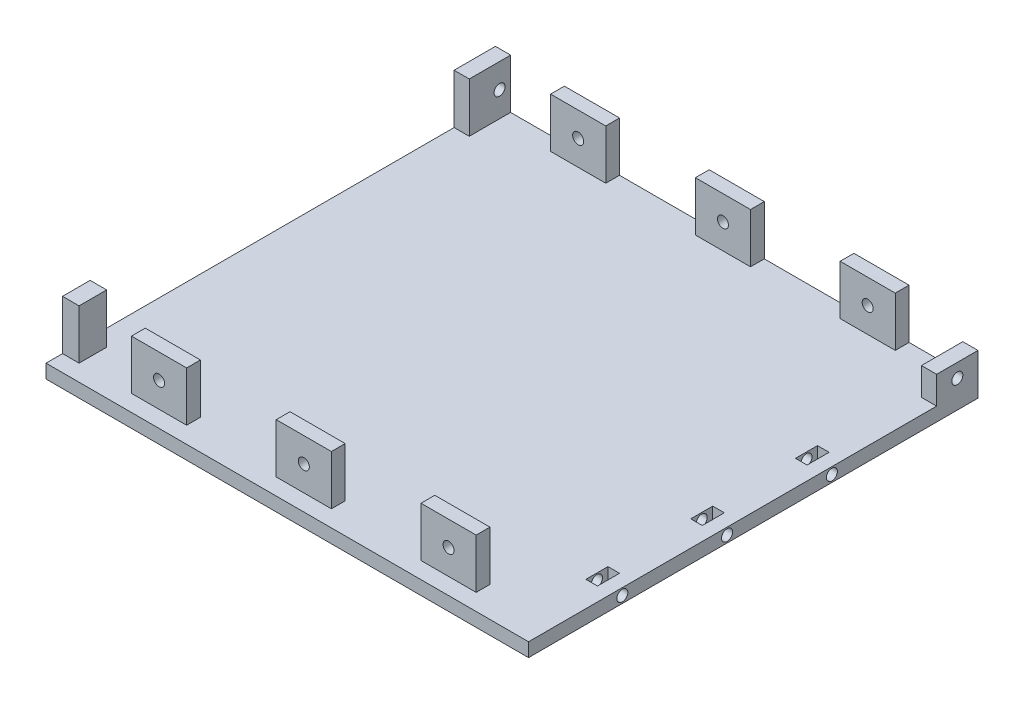
from build123d import *

# Parameters (mm, degrees)
SKETCH1_W               = 175
SKETCH1_H               = 163
BOSS_EXTRUDE1_DEPTH     = 5
SKETCH2_W               = 20
SKETCH2_H               = 5
BOSS_EXTRUDE2_DEPTH     = 18
SKETCH3_R               = 2
CUT_EXTRUDE1_DEPTH      = 7
CUT_EXTRUDE1_DEPTH_BACK = 158
SKETCH4_W               = 5.5
SKETCH4_H               = 15
SKETCH4_W_2             = 6
SKETCH4_H_2             = 10
BOSS_EXTRUDE3_DEPTH     = 18
SKETCH5_R               = 2
CUT_EXTRUDE2_DEPTH      = 18
SKETCH6_W               = 5.5
SKETCH6_H               = 15
BOSS_EXTRUDE4_DEPTH     = 10
SKETCH7_R               = 2
CUT_EXTRUDE3_DEPTH      = 10
SKETCH8_W               = 4.2
SKETCH8_H               = 8
CUT_EXTRUDE4_DEPTH      = 10
SKETCH9_R               = 2
CUT_EXTRUDE5_DEPTH      = 18


with BuildPart() as part:
    # Sketch1 → Boss-Extrude1 (new body)
    with BuildSketch(Plane(origin=(0, 0, 0), x_dir=(1, 0, 0), z_dir=(0, 1, 0))):
        with Locations((-64.046391753, -12.943298969)):
            Rectangle(SKETCH1_W, SKETCH1_H)
    extrude(amount=BOSS_EXTRUDE1_DEPTH)

    # Sketch2 → Boss-Extrude2 (add)
    with BuildSketch(Plane(origin=(0, 5, 0), x_dir=(1, 0, 0), z_dir=(0, 1, 0))):
        with Locations((-116.546391753, 66.056701031)):
            Rectangle(SKETCH2_W, SKETCH2_H)
        with Locations((-116.546391753, -85.943298969)):
            Rectangle(SKETCH2_W, SKETCH2_H)
        with Locations((-11.546391753, -85.943298969)):
            Rectangle(SKETCH2_W, SKETCH2_H)
        with Locations((-11.546391753, 66.056701031)):
            Rectangle(SKETCH2_W, SKETCH2_H)
        with Locations((-64.046391753, -85.943298969)):
            Rectangle(SKETCH2_W, SKETCH2_H)
        with Locations((-64.046391753, 66.056701031)):
            Rectangle(SKETCH2_W, SKETCH2_H)
    extrude(amount=BOSS_EXTRUDE2_DEPTH)

    # Sketch3 → Cut-Extrude1 (cut, two sides)
    with BuildSketch(Plane.XY.offset(88.443298969)) as cut_extrude1_sk:
        with Locations((-116.546391753, 14.1)):
            Circle(SKETCH3_R)
        with Locations((-64.046391753, 14.1)):
            Circle(SKETCH3_R)
        with Locations((-11.546391753, 14.1)):
            Circle(SKETCH3_R)
    extrude(amount=CUT_EXTRUDE1_DEPTH, mode=Mode.SUBTRACT)
    extrude(cut_extrude1_sk.sketch, amount=-CUT_EXTRUDE1_DEPTH_BACK, mode=Mode.SUBTRACT)

    # Sketch4 → Boss-Extrude3 (add)
    with BuildSketch(Plane(origin=(0, 5, 0), x_dir=(1, 0, 0), z_dir=(0, 1, 0))):
        with Locations((-148.796391753, 61.056701031)):
            Rectangle(SKETCH4_W, SKETCH4_H)
        with Locations((-148.546391753, -83.443298969)):
            Rectangle(SKETCH4_W_2, SKETCH4_H_2)
    extrude(amount=BOSS_EXTRUDE3_DEPTH)

    # Sketch5 → Cut-Extrude2 (cut)
    with BuildSketch(Plane(origin=(-146.046391753, 0, 0), x_dir=(0, 0, -1), z_dir=(1, 0, 0))):
        with Locations((64.556701031, 14.1)):
            Circle(SKETCH5_R)
    extrude(amount=-CUT_EXTRUDE2_DEPTH, mode=Mode.SUBTRACT)

    # Sketch6 → Boss-Extrude4 (add)
    with BuildSketch(Plane(origin=(0, 5, 0), x_dir=(1, 0, 0), z_dir=(0, 1, 0))):
        with Locations((20.703608247, 61.056701031)):
            Rectangle(SKETCH6_W, SKETCH6_H)
    extrude(amount=BOSS_EXTRUDE4_DEPTH)

    # Sketch7 → Cut-Extrude3 (cut)
    with BuildSketch(Plane(origin=(23.453608247, 0, 0), x_dir=(0, 0, -1), z_dir=(1, 0, 0))):
        with Locations((61.056701031, 10)):
            Circle(SKETCH7_R)
    extrude(amount=-CUT_EXTRUDE3_DEPTH, mode=Mode.SUBTRACT)

    # Sketch8 → Cut-Extrude4 (cut)
    with BuildSketch(Plane(origin=(0, 5, 0), x_dir=(1, 0, 0), z_dir=(0, 1, 0))):
        with Locations((16.353608247, -60.443298969)):
            Rectangle(SKETCH8_W, SKETCH8_H)
        with Locations((16.353608247, -22.443298969)):
            Rectangle(SKETCH8_W, SKETCH8_H)
        with Locations((16.353608247, 15.556701031)):
            Rectangle(SKETCH8_W, SKETCH8_H)
    extrude(amount=-CUT_EXTRUDE4_DEPTH, mode=Mode.SUBTRACT)

    # Sketch9 → Cut-Extrude5 (cut)
    with BuildSketch(Plane(origin=(23.453608247, 0, 0), x_dir=(0, 0, -1), z_dir=(1, 0, 0))):
        with Locations((-60.443298969, 2.5)):
            Circle(SKETCH9_R)
        with Locations((15.556701031, 2.5)):
            Circle(SKETCH9_R)
        with Locations((-22.443298969, 2.5)):
            Circle(SKETCH9_R)
    extrude(amount=-CUT_EXTRUDE5_DEPTH, mode=Mode.SUBTRACT)


solid = part.part
